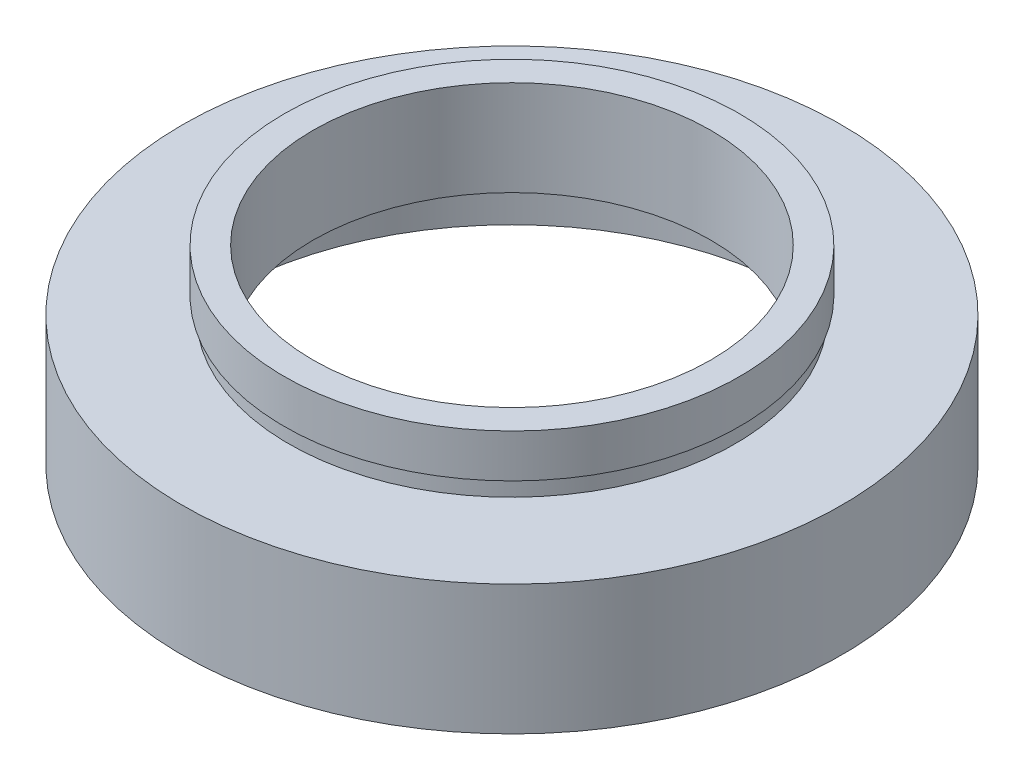
from build123d import *


with BuildPart() as part:
    # 草图1 → 旋转1 (revolve)
    with BuildSketch(Plane.XY, mode=Mode.PRIVATE) as revolve_1_sk:
        Polygon((17, 0), (17, 4.5), (17.6, 4.5), (17.6, 5.5), (11.5, 5.5), (11.5, 11), (13.16, 11), (13.16, 8.5), (12.9, 8.5), (12.9, 7.5), (19.05, 7.5), (19.05, 0), align=None)
    revolve(revolve_1_sk.sketch.rotate(Axis((0, 16.886018237, 0), (0, -1, 0)), 180), axis=Axis((0, 16.886018237, 0), (0, -1, 0)))  # turned: the seam where the file's is


solid = part.part
